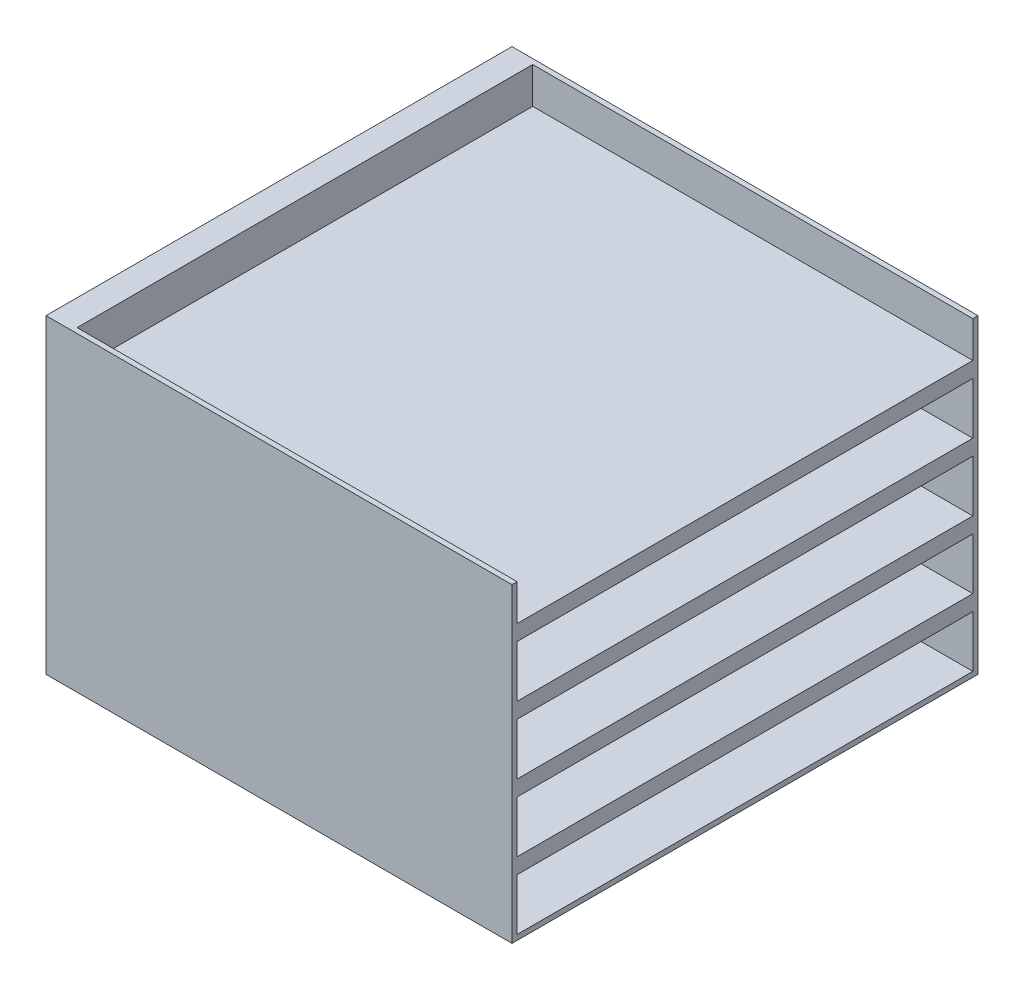
from build123d import *

# Parameters (mm, degrees)
SKETCH1_W           = 900
SKETCH1_H           = 900
BOSS_EXTRUDE1_DEPTH = 600
SKETCH3_W           = 880
SKETCH3_H           = 100
CUT_EXTRUDE2_DEPTH  = 850


with BuildPart() as part:
    # Sketch1 → Boss-Extrude1 (new body)
    with BuildSketch(Plane(origin=(0, 0, 0), x_dir=(1, 0, 0), z_dir=(0, 1, 0))):
        Rectangle(SKETCH1_W, SKETCH1_H)
    extrude(amount=BOSS_EXTRUDE1_DEPTH)

    # Sketch3 → Cut-Extrude2 (cut)
    with BuildSketch(Plane(origin=(450, 0, 0), x_dir=(0, 0, -1), z_dir=(1, 0, 0))):
        with Locations((0, 60)):
            Rectangle(SKETCH3_W, SKETCH3_H)
        with Locations((0, 190)):
            Rectangle(SKETCH3_W, SKETCH3_H)
        with Locations((0, 320)):
            Rectangle(SKETCH3_W, SKETCH3_H)
        with Locations((0, 450)):
            Rectangle(SKETCH3_W, SKETCH3_H)
        with Locations((0, 580)):
            Rectangle(SKETCH3_W, SKETCH3_H)
    extrude(amount=-CUT_EXTRUDE2_DEPTH, mode=Mode.SUBTRACT)


solid = part.part
